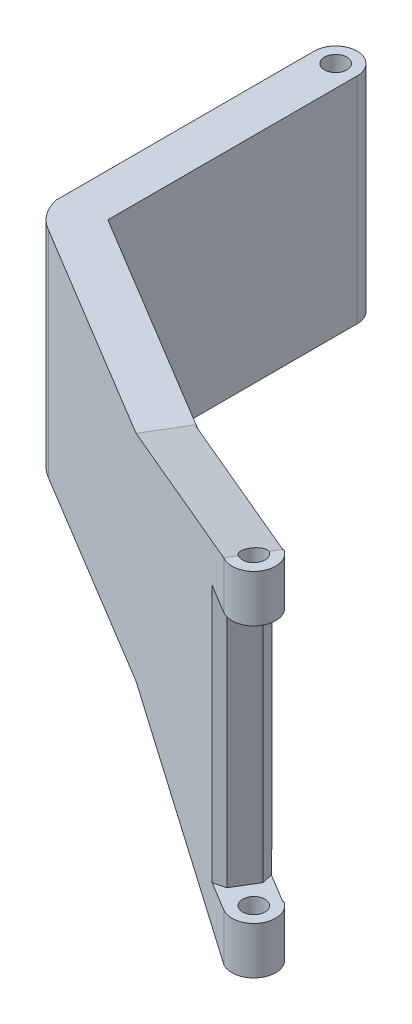
from build123d import *

# Parameters (mm, degrees)
SKETCH_1_R               = 2.5
SKETCH_1_R_2             = 1.3
EXTRUDE_1_DEPTH          = 25
EXTRUDE_2_DEPTH          = 25
EXTRUDE_3_DEPTH          = 8
EXTRUDE_3_DEPTH_BACK     = 33
EXTRUDE_4_DEPTH          = 5
SKETCH_4_R               = 1.3
CUT_EXTRUDE_1_DEPTH      = 92.24177093
CUT_EXTRUDE_1_DEPTH_BACK = 92.24177093
SKETCH_7_W               = 3
SKETCH_7_H               = 30
SKETCH_7_W_2             = 2.545959886
CUT_EXTRUDE_2_DEPTH      = 88.173473517
CUT_EXTRUDE_2_DEPTH_BACK = 9
CHAMFER_1_SIZE           = 1


with BuildPart() as part:
    # 草图1 → 凸台-拉伸1 (new body)
    with BuildSketch(Plane(origin=(0, 0, 0), x_dir=(1, 0, 0), z_dir=(0, 1, 0))):
        with Locations(Location((0, 0, 0), (0, 0, 270))):
            Circle(SKETCH_1_R)
        with Locations(Location((0, 0, 0), (0, 0, 270))):
            Circle(SKETCH_1_R_2, mode=Mode.SUBTRACT)
    extrude(amount=EXTRUDE_1_DEPTH)

    # 草图2 → 凸台-拉伸2 (add)
    with BuildSketch(Plane(origin=(0, 25, 0), x_dir=(1, 0, 0), z_dir=(0, 1, 0))):
        with BuildLine():
            ThreePointArc((2.5, 0), (0, -2.5), (-2.5, 0))
            Line((-2.5, 0), (-2.5, -30))
            ThreePointArc((-2.5, -30), (-1.63067791, -32.006781425), (0, -33.464101615))
            Line((0, -33.464101615), (51.335686519, -64.362639487))
            Line((51.335686519, -64.362639487), (53.961524227, -60))
            Line((53.961524227, -60), (2.5, -29.025721421))
            Line((2.5, -29.025721421), (2.5, 0))
        make_face()
    extrude(amount=-EXTRUDE_2_DEPTH)

    # 草图3 → 凸台-拉伸3 (add, two sides)
    with BuildSketch(Plane(origin=(0, 25, 0), x_dir=(1, 0, 0), z_dir=(0, 1, 0))) as extrude_3_sk:
        with BuildLine():
            Line((53.961524227, -60), (51.335686519, -64.362639487))
            ThreePointArc((51.335686519, -64.362639487), (54.829925117, -63.494238598), (53.961524227, -60))
        make_face()
    extrude(amount=EXTRUDE_3_DEPTH)
    extrude(extrude_3_sk.sketch, amount=-EXTRUDE_3_DEPTH_BACK)

    # 草图5 → 凸台-拉伸4 (add)
    with BuildSketch(Plane(origin=(-14.785406604, 0, 24.564883997), x_dir=(0.8567769491001666, 0, 0.5156871721214431), z_dir=(-0.5156871721214431, 0, 0.8567769491001666))):
        Polygon((77.174220423, 25), (77.174220423, 33), (47.215614176, 25), align=None)
    extrude_4 = extrude(amount=-EXTRUDE_4_DEPTH)

    # 镜向1: 凸台-拉伸4 across plane
    add(extrude_4.mirror(Plane(origin=(0, 12.5, 0), x_dir=(0, 0, 1), z_dir=(0, -1, 0))))

    # 草图4 → 切除-拉伸1 (cut, two sides)
    with BuildSketch(Plane(origin=(0, 25, 0), x_dir=(1, 0, 0), z_dir=(0, 1, 0))) as cut_extrude_1_sk:
        with Locations(Location((52.648605373, -62.181319744, 0), (0, 0, 238.956602405))):
            Circle(SKETCH_4_R)
    extrude(amount=CUT_EXTRUDE_1_DEPTH, mode=Mode.SUBTRACT)
    extrude(cut_extrude_1_sk.sketch, amount=-CUT_EXTRUDE_1_DEPTH_BACK, mode=Mode.SUBTRACT)

    # 草图7 → 切除-拉伸2 (cut, two sides)
    with BuildSketch(Plane(origin=(-14.785406604, 0, 24.564883997), x_dir=(0.8567769491001666, 0, 0.5156871721214431), z_dir=(-0.5156871721214431, 0, 0.8567769491001666))) as cut_extrude_2_sk:
        with Locations((75.674220423, 12.5)):
            Rectangle(SKETCH_7_W, SKETCH_7_H)
        with Locations((78.447200366, 12.5)):
            Rectangle(SKETCH_7_W_2, SKETCH_7_H)
    extrude(amount=CUT_EXTRUDE_2_DEPTH, mode=Mode.SUBTRACT)
    extrude(cut_extrude_2_sk.sketch, amount=-CUT_EXTRUDE_2_DEPTH_BACK, mode=Mode.SUBTRACT)

    # 倒角1
    chamfer_1_edges = [part.edges().sort_by_distance(p)[0] for p in [
        (48.765355672, 12.5, 62.815577971),
        (51.39119338, 12.5, 58.452938484),
    ]]
    chamfer(chamfer_1_edges, length=CHAMFER_1_SIZE)


solid = part.part
